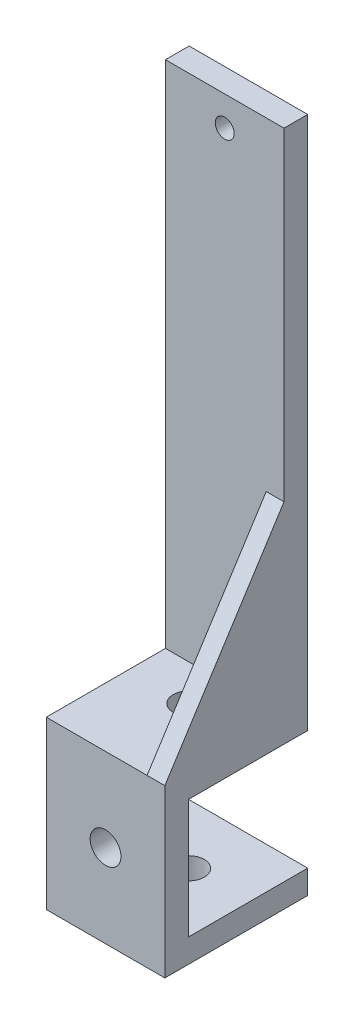
from build123d import *

# Parameters (mm, degrees)
SKETCH_1_W          = 20
SKETCH_1_H          = 90
EXTRUDE_1_DEPTH     = 4
SKETCH_2_W          = 20
SKETCH_2_H          = 4
EXTRUDE_2_DEPTH     = 20.1
SKETCH_3_W          = 20
SKETCH_3_H          = 4
EXTRUDE_3_DEPTH     = 24.1
SKETCH_4_W          = 20
SKETCH_4_H          = 4
EXTRUDE_4_DEPTH     = 20.1
SKETCH_5_R          = 2.6
CUT_EXTRUDE_1_DEPTH = 20
SKETCH_6_R          = 2.6
CUT_EXTRUDE_2_DEPTH = 20
SKETCH_7_R          = 2.6
CUT_EXTRUDE_3_DEPTH = 20
SKETCH_9_R          = 1.6
CUT_EXTRUDE_4_DEPTH = 20
EXTRUDE_5_DEPTH     = 3


with BuildPart() as part:
    # 草图1 → 凸台-拉伸1 (new body)
    with BuildSketch(Plane.XY):
        with Locations((-19.209677061, -2.260885663)):
            Rectangle(SKETCH_1_W, SKETCH_1_H)
    extrude(amount=EXTRUDE_1_DEPTH)

    # 草图2 → 凸台-拉伸2 (add)
    with BuildSketch(Plane.XY.offset(4)):
        with Locations((-19.209677061, -45.260885663)):
            Rectangle(SKETCH_2_W, SKETCH_2_H)
    extrude(amount=EXTRUDE_2_DEPTH)

    # 草图3 → 凸台-拉伸3 (add)
    with BuildSketch(Plane(origin=(0, -47.260885663, 0), x_dir=(-1, 0, 0), z_dir=(0, -1, 0))):
        with Locations((19.209677061, -22.1)):
            Rectangle(SKETCH_3_W, SKETCH_3_H)
    extrude(amount=EXTRUDE_3_DEPTH)

    # 草图4 → 凸台-拉伸4 (add)
    with BuildSketch(Plane(origin=(0, 0, 20.1), x_dir=(-1, 0, 0), z_dir=(0, 0, -1))):
        with Locations((19.209677061, -69.360885663)):
            Rectangle(SKETCH_4_W, SKETCH_4_H)
    extrude(amount=EXTRUDE_4_DEPTH)

    # 草图5 → 切除-拉伸1 (cut)
    with BuildSketch(Plane(origin=(0, -47.260885663, 0), x_dir=(-1, 0, 0), z_dir=(0, -1, 0))):
        with Locations((19.209677061, -10.094759339)):
            Circle(SKETCH_5_R)
    extrude(amount=-CUT_EXTRUDE_1_DEPTH, mode=Mode.SUBTRACT)

    # 草图6 → 切除-拉伸2 (cut)
    with BuildSketch(Plane(origin=(0, 0, 20.1), x_dir=(-1, 0, 0), z_dir=(0, 0, -1))):
        with Locations((19.209677061, -57.310885663)):
            Circle(SKETCH_6_R)
    extrude(amount=-CUT_EXTRUDE_2_DEPTH, mode=Mode.SUBTRACT)

    # 草图7 → 切除-拉伸3 (cut)
    with BuildSketch(Plane(origin=(0, -67.360885663, 0), x_dir=(1, 0, 0), z_dir=(0, 1, 0))):
        with Locations((-19.209677061, -10.05)):
            Circle(SKETCH_7_R)
    extrude(amount=-CUT_EXTRUDE_3_DEPTH, mode=Mode.SUBTRACT)

    # 草图9 → 切除-拉伸4 (cut)
    with BuildSketch(Plane(origin=(0, 0, 0), x_dir=(-1, 0, 0), z_dir=(0, 0, -1))):
        with Locations((19.209677061, 37.739114337)):
            Circle(SKETCH_9_R)
        with Locations((19.209677061, -38.260885663)):
            Circle(SKETCH_9_R)
    extrude(amount=-CUT_EXTRUDE_4_DEPTH, mode=Mode.SUBTRACT)

    # 草图10 → 凸台-拉伸5 (add)
    with BuildSketch(Plane(origin=(-9.209677061, 0, 0), x_dir=(0, 0, -1), z_dir=(1, 0, 0))):
        Polygon((-4, -11.848280973), (-24.1, -43.260885663), (-4, -43.260885663), align=None)
    extrude(amount=-EXTRUDE_5_DEPTH)


solid = part.part
